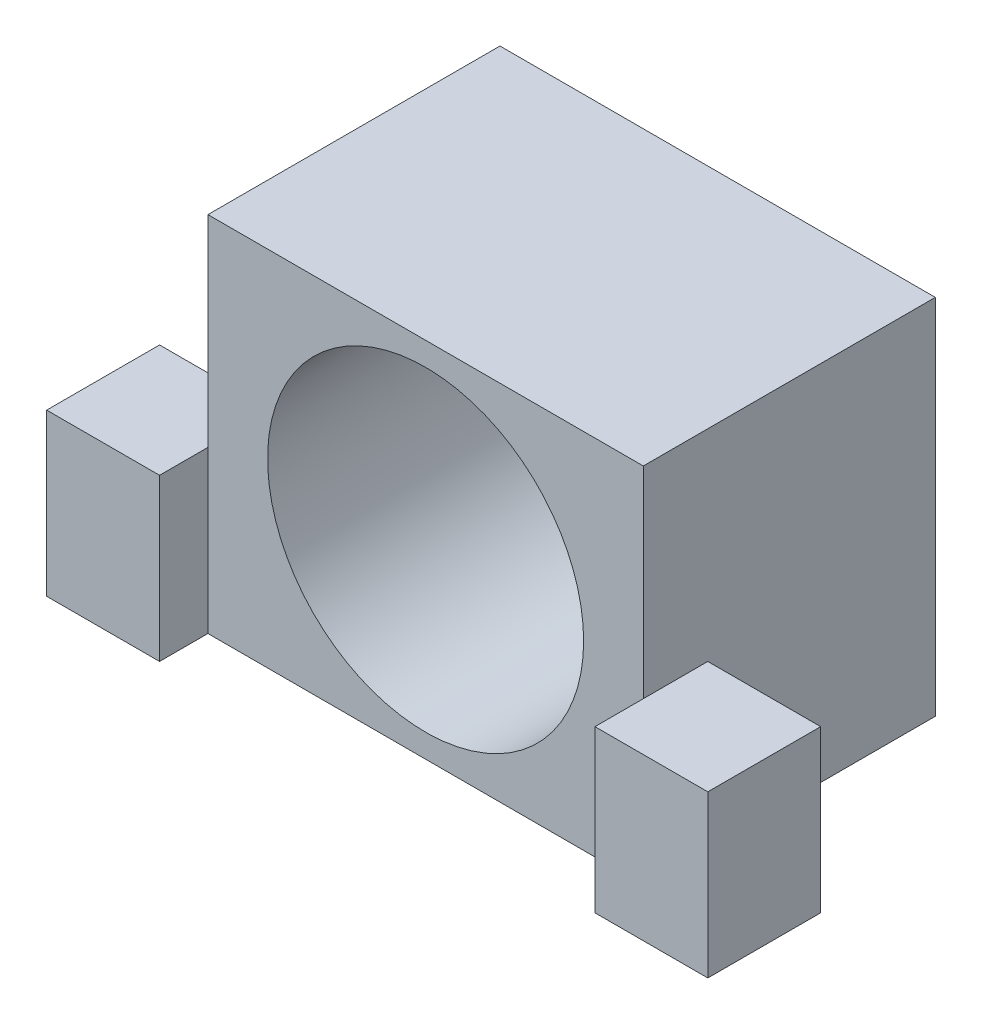
from build123d import *

# Parameters (mm, degrees)
SKETCH1_W                = 34.29
SKETCH1_H                = 28.575
BOSS_EXTRUDE1_DEPTH      = 23
SKETCH3_R                = 12.446
CUT_EXTRUDE1_DEPTH       = 21
SKETCH5_R                = 1.625
SKETCH5_R_2              = 3.75
CUT_EXTRUDE2_DEPTH       = 3
SKETCH7_W                = 8.89
SKETCH7_H                = 12.7
BOSS_EXTRUDE2_DEPTH      = 3.81
BOSS_EXTRUDE2_DEPTH_BACK = 5.08


with BuildPart() as part:
    # Sketch1 → Boss-Extrude1 (new body)
    with BuildSketch(Plane.XY):
        Rectangle(SKETCH1_W, SKETCH1_H)
    extrude(amount=BOSS_EXTRUDE1_DEPTH)

    # Sketch3 → Cut-Extrude1 (cut)
    with BuildSketch(Plane.XY.offset(23)):
        Circle(SKETCH3_R)
    extrude(amount=-CUT_EXTRUDE1_DEPTH, mode=Mode.SUBTRACT)

    # Sketch5 → Cut-Extrude2 (cut, through all)
    with BuildSketch(Plane.XY.offset(2)):
        with Locations((0, 8.5)):
            Circle(SKETCH5_R)
        with Locations((-8.5, 0)):
            Circle(SKETCH5_R)
        with Locations((8.5, 0)):
            Circle(SKETCH5_R)
        with Locations((0, -8.5)):
            Circle(SKETCH5_R)
        Circle(SKETCH5_R_2)
    extrude(amount=-CUT_EXTRUDE2_DEPTH, mode=Mode.SUBTRACT)

    # Sketch7 → Boss-Extrude2 (add, two sides)
    with BuildSketch(Plane.XY.offset(23)) as boss_extrude2_sk:
        with Locations((-21.59, -7.9375)):
            Rectangle(SKETCH7_W, SKETCH7_H)
        with Locations((21.59, -7.9375)):
            Rectangle(SKETCH7_W, SKETCH7_H)
    extrude(amount=BOSS_EXTRUDE2_DEPTH)
    extrude(boss_extrude2_sk.sketch, amount=-BOSS_EXTRUDE2_DEPTH_BACK)


solid = part.part
